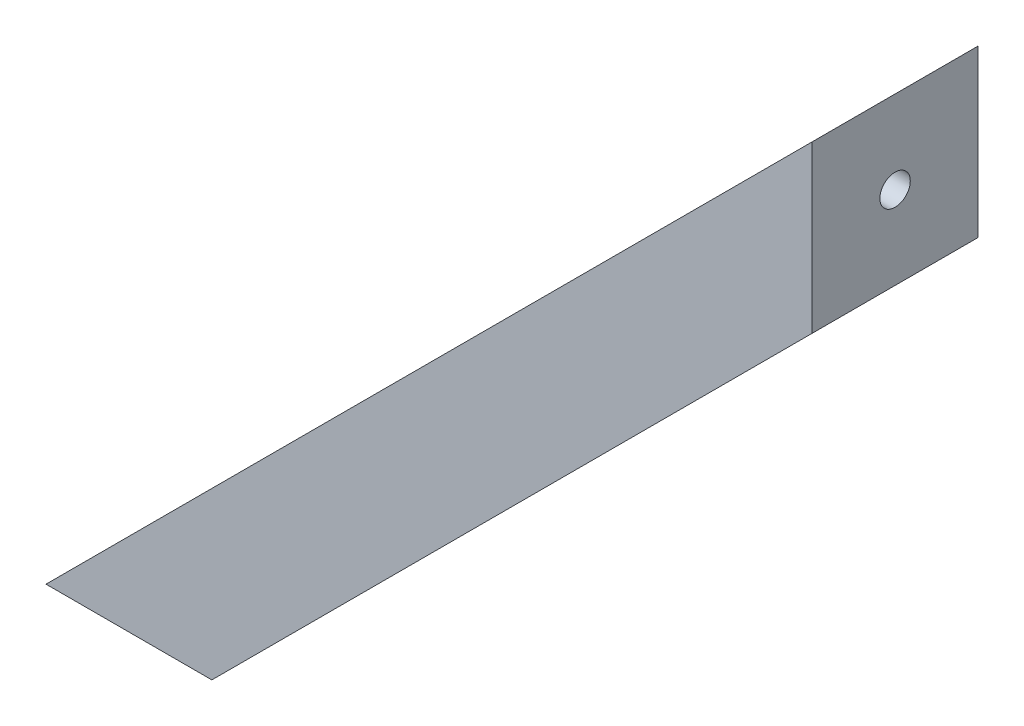
from build123d import *

# Parameters (mm, degrees)
BOSS_EXTRUDE1_DEPTH = 38.1
SHELL1_T            = -6.35
SKETCH3_R           = 3.4925
CUT_EXTRUDE1_DEPTH  = 6.35
SKETCH4_R           = 3.4925
CUT_EXTRUDE2_DEPTH  = 59.436
SKETCH6_W           = 25.4
SKETCH6_H           = 6.35
BOSS_EXTRUDE2_DEPTH = 26.940768


with BuildPart() as part:
    # Sketch1 → Boss-Extrude1 (new body)
    with BuildSketch(Plane.XY):
        Polygon((0, 0), (176.013019973, 176.013019973), (176.013019973, 137.913019973), (38.1, 0), align=None)
    extrude(amount=BOSS_EXTRUDE1_DEPTH)

    # Shell1
    shell1_openings = [part.faces().sort_by_distance(p)[0] for p in [
        (88.006509986, 88.006509986, 19.05),
    ]]
    offset(amount=SHELL1_T, openings=shell1_openings, kind=Kind.INTERSECTION)

    # Sketch3 → Cut-Extrude1 (cut)
    with BuildSketch(Plane.XZ):
        with Locations((19.05, 19.05)):
            Circle(SKETCH3_R)
    extrude(amount=-CUT_EXTRUDE1_DEPTH, mode=Mode.SUBTRACT)

    # Sketch4 → Cut-Extrude2 (cut)
    with BuildSketch(Plane(origin=(176.013019973, 0, 0), x_dir=(0, 0, -1), z_dir=(1, 0, 0))):
        with Locations((-19.05, 156.963019973)):
            Circle(SKETCH4_R)
    extrude(amount=-CUT_EXTRUDE2_DEPTH, mode=Mode.SUBTRACT)

    # Sketch6 → Boss-Extrude2 (add)
    with BuildSketch(Plane(origin=(0, 0, 0), x_dir=(0, 0, 1), z_dir=(-0.707106781, 0.707106781, 0))):
        with Locations((19.05, 124.333)):
            Rectangle(SKETCH6_W, SKETCH6_H)
        with Locations((19.05, 175.133)):
            Rectangle(SKETCH6_W, SKETCH6_H)
        with Locations((19.05, 73.533)):
            Rectangle(SKETCH6_W, SKETCH6_H)
    extrude(amount=-BOSS_EXTRUDE2_DEPTH)


solid = part.part
